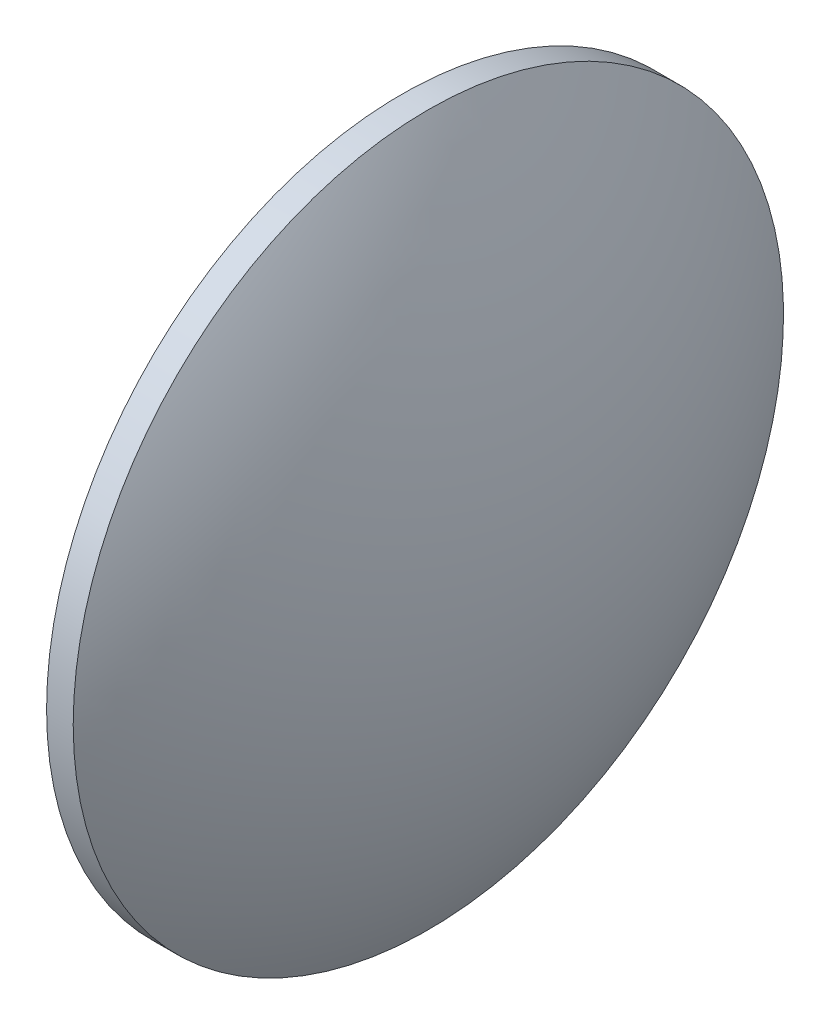
from build123d import *


with BuildPart() as part:
    # 草图1 → 旋转1 (revolve)
    with BuildSketch(Plane.XY):
        with BuildLine():
            Line((225.949094224, 130.467109853), (225.949094224, 170.467109853))
            Line((225.949094224, 170.467109853), (228.949094224, 170.467109853))
            ThreePointArc((228.949094224, 170.467109853), (237.237362271, 151.22556837), (240.069094224, 130.467109853))
            Line((240.069094224, 130.467109853), (225.949094224, 130.467109853))
        make_face()
    revolve(axis=Axis((217.994582532, 130.467109853, 0), (1, 0, 0)))


solid = part.part
